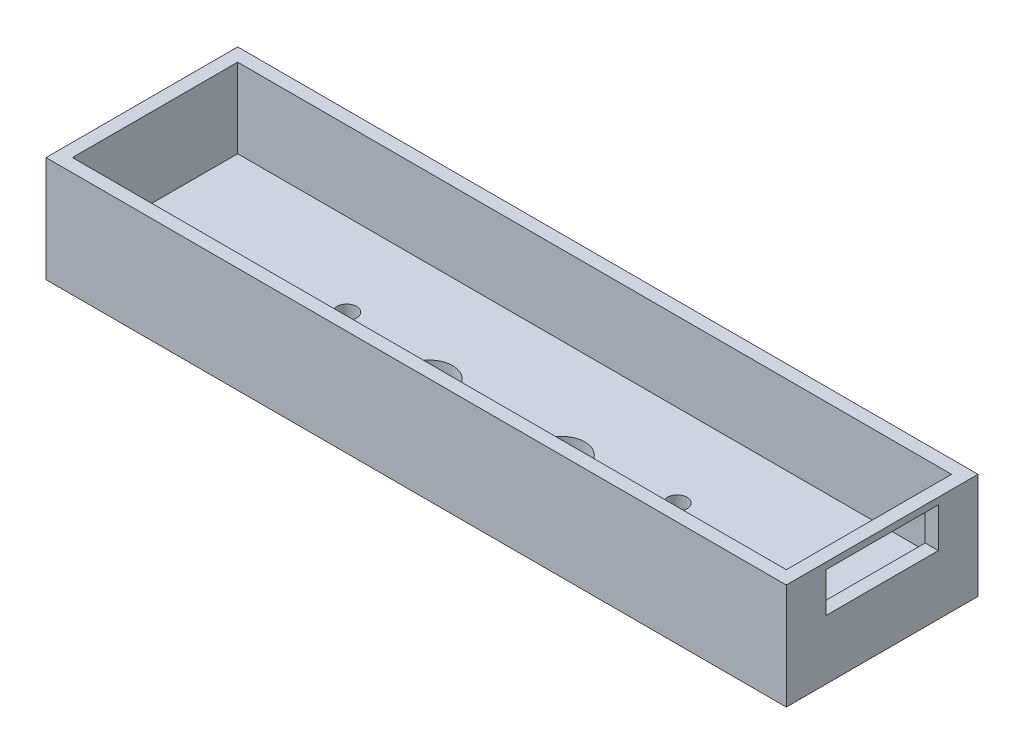
from build123d import *

# Parameters (mm, degrees)
SKETCH1_W                = 108
SKETCH1_H                = 25
BOSS_EXTRUDE1_DEPTH      = 4
CUT_EXTRUDE1_REACH       = 6
SKETCH2_R                = 1.5
SKETCH3_R                = 3.5
SKETCH3_R_2              = 1.5
CUT_EXTRUDE3_DEPTH       = 2
CUT_EXTRUDE4_REACH       = 6
SKETCH4_R                = 1.25
SKETCH5_R                = 3.5
CUT_EXTRUDE5_DEPTH       = 1.7
SKETCH6_W                = 112
SKETCH6_H                = 29
SKETCH6_W_2              = 108
SKETCH6_H_2              = 25
BOSS_EXTRUDE2_DEPTH      = 12
BOSS_EXTRUDE2_DEPTH_BACK = 4
CUT_EXTRUDE8_REACH       = 114
SKETCH10_W               = 17
SKETCH10_H               = 6


with BuildPart() as part:
    # Sketch1 → Boss-Extrude1 (new body)
    with BuildSketch(Plane(origin=(0, 0, 0), x_dir=(1, 0, 0), z_dir=(0, 1, 0))):
        with Locations((11.544540658, 6.287491884)):
            Rectangle(SKETCH1_W, SKETCH1_H)
    extrude(amount=BOSS_EXTRUDE1_DEPTH)

    # Sketch2 → Cut-Extrude1 (cut, up to next)
    with BuildSketch(Plane(origin=(0, 4, 0), x_dir=(1, 0, 0), z_dir=(0, 1, 0)), mode=Mode.PRIVATE) as cut_extrude1_sk1:
        with Locations((-13.455459342, 6.287491884)):
            Circle(SKETCH2_R)
    cut_extrude1_tool1 = extrude(cut_extrude1_sk1.sketch, amount=-CUT_EXTRUDE1_REACH, mode=Mode.PRIVATE) & part.part
    add(cut_extrude1_tool1.solids().sort_by_distance((-13.455459, 4, -6.287492))[0], mode=Mode.SUBTRACT)
    # Sketch2 → Cut-Extrude1 (cut, up to next)
    with BuildSketch(Plane(origin=(0, 4, 0), x_dir=(1, 0, 0), z_dir=(0, 1, 0)), mode=Mode.PRIVATE) as cut_extrude1_sk2:
        with Locations((36.544540658, 6.287491884)):
            Circle(SKETCH2_R)
    cut_extrude1_tool2 = extrude(cut_extrude1_sk2.sketch, amount=-CUT_EXTRUDE1_REACH, mode=Mode.PRIVATE) & part.part
    add(cut_extrude1_tool2.solids().sort_by_distance((36.544541, 4, -6.287492))[0], mode=Mode.SUBTRACT)

    # Sketch3 → Cut-Extrude3 (cut)
    with BuildSketch(Plane(origin=(0, 0, 0), x_dir=(-1, 0, 0), z_dir=(0, -1, 0))):
        with Locations((13.455459342, 6.287491884)):
            Circle(SKETCH3_R)
        with Locations((13.455459342, 6.287491884)):
            Circle(SKETCH3_R_2, mode=Mode.SUBTRACT)
        with Locations((-36.544540658, 6.287491884)):
            Circle(SKETCH3_R)
    extrude(amount=-CUT_EXTRUDE3_DEPTH, mode=Mode.SUBTRACT)

    # Sketch4 → Cut-Extrude4 (cut, up to next)
    with BuildSketch(Plane(origin=(0, 4, 0), x_dir=(1, 0, 0), z_dir=(0, 1, 0)), mode=Mode.PRIVATE) as cut_extrude4_sk1:
        with Locations((21.544540658, 3.787491884)):
            Circle(SKETCH4_R)
    cut_extrude4_tool1 = extrude(cut_extrude4_sk1.sketch, amount=-CUT_EXTRUDE4_REACH, mode=Mode.PRIVATE) & part.part
    add(cut_extrude4_tool1.solids().sort_by_distance((21.544541, 4, -3.787492))[0], mode=Mode.SUBTRACT)
    # Sketch4 → Cut-Extrude4 (cut, up to next)
    with BuildSketch(Plane(origin=(0, 4, 0), x_dir=(1, 0, 0), z_dir=(0, 1, 0)), mode=Mode.PRIVATE) as cut_extrude4_sk2:
        with Locations((1.544540658, 3.787491884)):
            Circle(SKETCH4_R)
    cut_extrude4_tool2 = extrude(cut_extrude4_sk2.sketch, amount=-CUT_EXTRUDE4_REACH, mode=Mode.PRIVATE) & part.part
    add(cut_extrude4_tool2.solids().sort_by_distance((1.544541, 4, -3.787492))[0], mode=Mode.SUBTRACT)

    # Sketch5 → Cut-Extrude5 (cut)
    with BuildSketch(Plane(origin=(0, 4, 0), x_dir=(1, 0, 0), z_dir=(0, 1, 0))):
        with Locations((21.544540658, 3.787491884)):
            Circle(SKETCH5_R)
        with Locations((1.544540658, 3.787491884)):
            Circle(SKETCH5_R)
    extrude(amount=-CUT_EXTRUDE5_DEPTH, mode=Mode.SUBTRACT)

    # Sketch6 → Boss-Extrude2 (add, two sides)
    with BuildSketch(Plane(origin=(0, 4, 0), x_dir=(1, 0, 0), z_dir=(0, 1, 0))) as boss_extrude2_sk:
        with Locations((11.544540658, 6.287491884)):
            Rectangle(SKETCH6_W, SKETCH6_H)
        with Locations((11.544540658, 6.287491884)):
            Rectangle(SKETCH6_W_2, SKETCH6_H_2, mode=Mode.SUBTRACT)
    extrude(amount=BOSS_EXTRUDE2_DEPTH)
    extrude(boss_extrude2_sk.sketch, amount=-BOSS_EXTRUDE2_DEPTH_BACK)

    # Sketch10 → Cut-Extrude8 (cut, up to next)
    with BuildSketch(Plane(origin=(67.544540658, 0, 0), x_dir=(0, 0, -1), z_dir=(1, 0, 0)), mode=Mode.PRIVATE) as cut_extrude8_sk1:
        with Locations((6.287491884, 12)):
            Rectangle(SKETCH10_W, SKETCH10_H)
    cut_extrude8_tool1 = extrude(cut_extrude8_sk1.sketch, amount=-CUT_EXTRUDE8_REACH, mode=Mode.PRIVATE) & part.part
    add(cut_extrude8_tool1.solids().sort_by_distance((67.544541, 12, -6.287492))[0], mode=Mode.SUBTRACT)


solid = part.part
